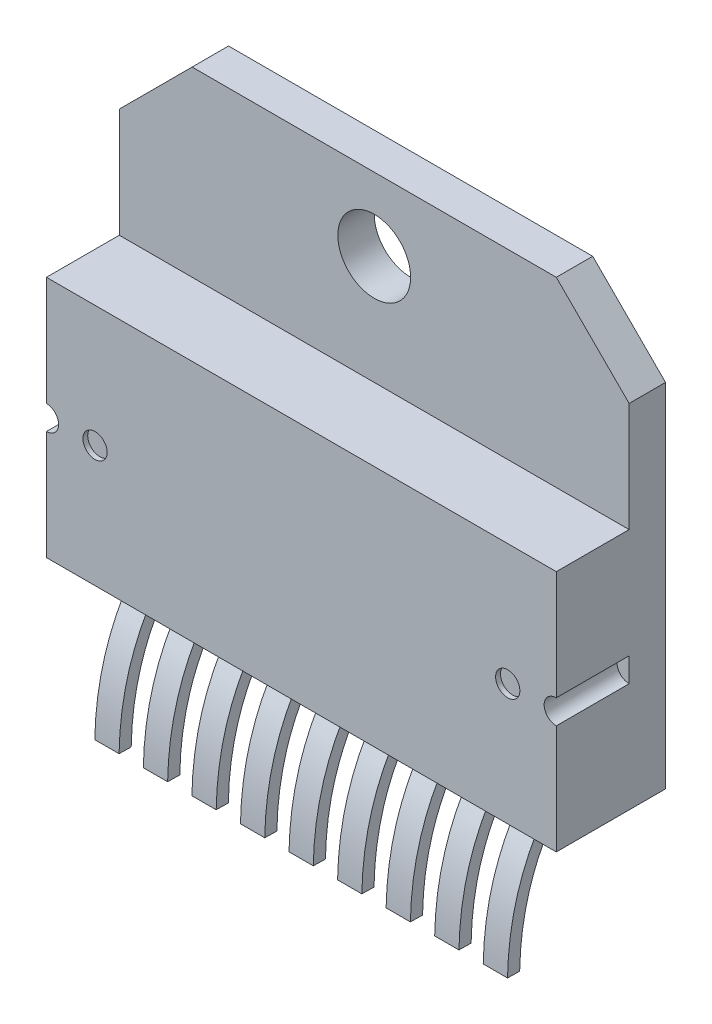
from build123d import *

# Parameters (mm, degrees)
Y_KSEKLIK_EKSTR_ZYON1_DEPTH      = 1.5
IZIM2_W                          = 21
IZIM2_H                          = 10
Y_KSEKLIK_EKSTR_ZYON2_DEPTH      = 3
KES_EKSTR_ZYON1_DEPTH            = 3
IZIM4_R                          = 0.5
KES_EKSTR_ZYON2_DEPTH            = 0.2
Y_KSEKLIK_EKSTR_ZYON3_DEPTH      = 10
Y_KSEKLIK_EKSTR_ZYON3_DEPTH_BACK = 10
KES_EKSTR_ZYON3_DEPTH            = 10
IZIM9_R                          = 1.5
KES_EKSTR_ZYON4_DEPTH            = 10


with BuildPart() as part:
    # Çizim1 → Yükseklik-Ekstrüzyon1 (new body)
    with BuildSketch(Plane.XY):
        Polygon((-10.5, 5.75), (-7.5, 8.75), (7.5, 8.75), (10.5, 5.75), (10.5, -8.75), (-10.5, -8.75), align=None)
    extrude(amount=Y_KSEKLIK_EKSTR_ZYON1_DEPTH)

    # Çizim2 → Yükseklik-Ekstrüzyon2 (add)
    with BuildSketch(Plane.XY.offset(1.5)):
        with Locations((0, -3.75)):
            Rectangle(IZIM2_W, IZIM2_H)
    extrude(amount=Y_KSEKLIK_EKSTR_ZYON2_DEPTH)

    # Çizim3 → Kes-Ekstrüzyon1 (cut)
    with BuildSketch(Plane.XY.offset(4.5)):
        with BuildLine():
            Line((-10.5, -3.25), (-10.5, -4.25))
            ThreePointArc((-10.5, -4.25), (-10, -3.75), (-10.5, -3.25))
        make_face()
        with BuildLine():
            Line((10.5, -3.25), (10.5, -4.25))
            ThreePointArc((10.5, -4.25), (10, -3.75), (10.5, -3.25))
        make_face()
    extrude(amount=-KES_EKSTR_ZYON1_DEPTH, mode=Mode.SUBTRACT)

    # Çizim4 → Kes-Ekstrüzyon2 (cut)
    with BuildSketch(Plane.XY.offset(4.5)):
        with Locations((-8.5, -3.75)):
            Circle(IZIM4_R)
        with Locations((8.5, -3.75)):
            Circle(IZIM4_R)
    extrude(amount=-KES_EKSTR_ZYON2_DEPTH, mode=Mode.SUBTRACT)

    # Çizim5 → Yükseklik-Ekstrüzyon3 (add, two sides)
    with BuildSketch(Plane(origin=(0, 0, 0), x_dir=(0, 0, -1), z_dir=(1, 0, 0))) as y_kseklik_ekstr_zyon3_sk:
        with BuildLine():
            Line((-2.121056986, -8.114958286), (-1.763284227, -8.464241342))
            add(Edge.make_bspline(
                [(-4.000086505, -14.259300429), (-3.994612568, -13.965067214), (-3.960806645, -13.366672985), (-3.805455262, -12.259533496), (-3.446184905, -10.981070899), (-2.76204135, -9.632169884), (-2.11843608, -8.828025544), (-1.763284227, -8.464241342)],
                knots=[0, 0, 0, 0, 0.125, 0.25, 0.5, 0.75, 1, 1, 1, 1], degree=3))
            Line((-4.000086505, -14.259300429), (-4.5, -14.25))
            add(Edge.make_bspline(
                [(-4.5, -14.25), (-4.429860392, -10.479879656), (-2.121056986, -8.114958286)],
                knots=[0, 0, 0, 1, 1, 1], degree=2))
        make_face()
    extrude(amount=Y_KSEKLIK_EKSTR_ZYON3_DEPTH)
    extrude(y_kseklik_ekstr_zyon3_sk.sketch, amount=-Y_KSEKLIK_EKSTR_ZYON3_DEPTH_BACK)

    # Çizim8 → Kes-Ekstrüzyon3 (cut)
    with BuildSketch(Plane.XY.offset(7)):
        Polygon((-8.509588272, -14.25), (-8.509588272, -8.75), (-9.509588272, -8.75), (-10, -8.75), (-10, -14.25), (-10, -14.939663009), (-8.509588272, -14.939663009), align=None)
        Polygon((-6.509588272, -8.75), (-7.509588272, -8.75), (-7.509588272, -14.25), (-7.509588272, -14.939663009), (-6.509588272, -14.939663009), (-6.509588272, -14.25), align=None)
        Polygon((-4.509588272, -8.75), (-5.509588272, -8.75), (-5.509588272, -14.25), (-5.509588272, -14.939663009), (-4.509588272, -14.939663009), (-4.509588272, -14.25), align=None)
        Polygon((-2.509588272, -8.75), (-3.509588272, -8.75), (-3.509588272, -14.25), (-3.509588272, -14.939663009), (-2.509588272, -14.939663009), (-2.509588272, -14.25), align=None)
        Polygon((-1.509588272, -14.939663009), (-0.509588272, -14.939663009), (-0.509588272, -14.25), (-0.509588272, -8.75), (-1.509588272, -8.75), (-1.509588272, -14.25), align=None)
        Polygon((0.490411728, -14.939663009), (1.490411728, -14.939663009), (1.490411728, -14.25), (1.490411728, -8.75), (0.490411728, -8.75), (0.490411728, -14.25), align=None)
        Polygon((3.490411728, -8.75), (2.490411728, -8.75), (2.490411728, -14.25), (2.490411728, -14.939663009), (3.490411728, -14.939663009), (3.490411728, -14.25), align=None)
        Polygon((5.490411728, -8.75), (4.490411728, -8.75), (4.490411728, -14.25), (4.490411728, -14.939663009), (5.490411728, -14.939663009), (5.490411728, -14.25), align=None)
        Polygon((7.490411728, -8.75), (6.490411728, -8.75), (6.490411728, -14.25), (6.490411728, -14.939663009), (7.490411728, -14.939663009), (7.490411728, -14.25), align=None)
        Polygon((9.490411728, -8.75), (8.490411728, -8.75), (8.490411728, -14.25), (8.490411728, -14.939663009), (10, -14.939663009), (10, -14.25), (10, -8.75), align=None)
    extrude(amount=-KES_EKSTR_ZYON3_DEPTH, mode=Mode.SUBTRACT)

    # Çizim9 → Kes-Ekstrüzyon4 (cut)
    with BuildSketch(Plane.XY.offset(1.5)):
        with Locations((0, 5.75)):
            Circle(IZIM9_R)
    extrude(amount=-KES_EKSTR_ZYON4_DEPTH, mode=Mode.SUBTRACT)


solid = part.part
